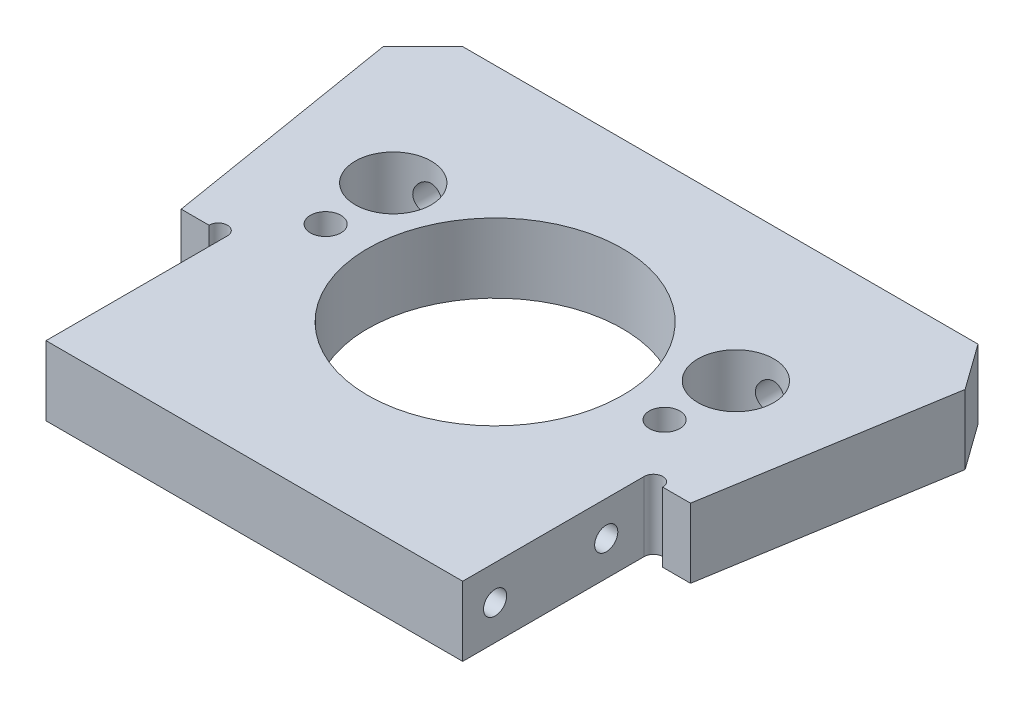
from build123d import *
from OCP.BRepFilletAPI import BRepFilletAPI_MakeChamfer

# Parameters (mm, degrees)
BOSS_EXTRUDE1_DEPTH            = 7.5
CUT_EXTRUDE1_REACH             = 58.013
SKETCH2_R                      = 1
CUT_EXTRUDE1_DIRECTION_2_DEPTH = 57.013391256
CHAMFER1_SIZE                  = 5
CHAMFER1_SIZE2                 = 4.351474633
CUT_EXTRUDE2_REACH             = 57.607
SKETCH3_R                      = 13.75
SKETCH11_W                     = 45
SKETCH11_H                     = 7.5
BOSS_EXTRUDE2_DEPTH            = 5
M4_TAPPED_HOLE1_D              = 3.3
CUT_EXTRUDE3_REACH             = 57.607
SKETCH6_R                      = 4.1
M4_TAPPED_HOLE2_REACH          = 61.725
M4_TAPPED_HOLE2_BORE_R         = 1.65
M3_TAPPED_HOLE1_AT_2_COUNT     = 2
M3_TAPPED_HOLE1_AT_2_PITCH     = 12


with BuildPart() as part:
    # Sketch1 → Boss-Extrude1 (new body)
    with BuildSketch(Plane(origin=(0, 0, 0), x_dir=(1, 0, 0), z_dir=(0, 1, 0))):
        Polygon((-22.5, 0), (22.5, 0), (22.5, 14.6), (27.5, 14.6), (32.5, 45), (-32.5, 45), (-27.5, 14.6), (-22.5, 14.6), align=None)
    extrude(amount=BOSS_EXTRUDE1_DEPTH)

    # Sketch2 → Cut-Extrude1 (cut, up to next)
    with BuildSketch(Plane(origin=(0, 7.5, 0), x_dir=(1, 0, 0), z_dir=(0, 1, 0)), mode=Mode.PRIVATE) as cut_extrude1_sk1:
        with Locations((-23.5, 14.6)):
            Circle(SKETCH2_R)
    cut_extrude1_tool1 = extrude(cut_extrude1_sk1.sketch, amount=-CUT_EXTRUDE1_REACH, mode=Mode.PRIVATE) & part.part
    # Sketch2 → Cut-Extrude1 (cut, up to next)
    with BuildSketch(Plane(origin=(0, 7.5, 0), x_dir=(1, 0, 0), z_dir=(0, 1, 0)), mode=Mode.PRIVATE) as cut_extrude1_sk2:
        with Locations((23.5, 14.6)):
            Circle(SKETCH2_R)
    cut_extrude1_tool2 = extrude(cut_extrude1_sk2.sketch, amount=-CUT_EXTRUDE1_REACH, mode=Mode.PRIVATE) & part.part
    add(cut_extrude1_tool1.solids().sort_by_distance((-23.5, 7.5, -14.6))[0], mode=Mode.SUBTRACT)
    add(cut_extrude1_tool2.solids().sort_by_distance((23.5, 7.5, -14.6))[0], mode=Mode.SUBTRACT)

    # Sketch2 → Cut-Extrude1 direction 2 (cut)
    with BuildSketch(Plane(origin=(0, 7.5, 0), x_dir=(1, 0, 0), z_dir=(0, 1, 0))):
        with Locations((-23.5, 14.6)):
            Circle(SKETCH2_R)
        with Locations((23.5, 14.6)):
            Circle(SKETCH2_R)
    extrude(amount=CUT_EXTRUDE1_DIRECTION_2_DEPTH, mode=Mode.SUBTRACT)

    # Chamfer1: one chamfer whose edges measure the first distance from different faces: ONE call of the kernel's chamfer builder (chamfer() names one face for all edges)
    chamfer1_edges_1 = [part.edges().sort_by_distance(p)[0] for p in [
        (-32.5, 3.75, -45),
    ]]
    chamfer1_side_1 = [part.faces().sort_by_distance(p)[0] for p in [
        (0, 3.75, -45),
    ]]
    chamfer1_edges_2 = [part.edges().sort_by_distance(p)[0] for p in [
        (32.5, 3.75, -45),
    ]]
    chamfer1_side_2 = [part.faces().sort_by_distance(p)[0] for p in [
        (30, 3.75, -29.8),
    ]]
    chamfer1 = BRepFilletAPI_MakeChamfer(part.part.solid().wrapped)
    for e in chamfer1_edges_1:
        chamfer1.Add(CHAMFER1_SIZE, CHAMFER1_SIZE2, e.wrapped, chamfer1_side_1[0].wrapped)  # the first distance lies on this face
    for e in chamfer1_edges_2:
        chamfer1.Add(CHAMFER1_SIZE, CHAMFER1_SIZE2, e.wrapped, chamfer1_side_2[0].wrapped)  # the first distance lies on this face
    add(Compound.cast(chamfer1.Shape()), mode=Mode.REPLACE)

    # Sketch3 → Cut-Extrude2 (cut, up to next)
    with BuildSketch(Plane(origin=(0, 7.5, 0), x_dir=(1, 0, 0), z_dir=(0, 1, 0)), mode=Mode.PRIVATE) as cut_extrude2_sk1:
        with Locations(Location((0, 21, 0), (0, 0, 270))):
            Circle(SKETCH3_R)
    cut_extrude2_tool1 = extrude(cut_extrude2_sk1.sketch, amount=-CUT_EXTRUDE2_REACH, mode=Mode.PRIVATE) & part.part
    add(cut_extrude2_tool1.solids().sort_by_distance((0, 7.5, -21))[0], mode=Mode.SUBTRACT)

    # Sketch11 → Boss-Extrude2 (add)
    with BuildSketch(Plane.XY):
        with Locations((0, 3.75)):
            Rectangle(SKETCH11_W, SKETCH11_H)
    extrude(amount=BOSS_EXTRUDE2_DEPTH)

    # M4 Tapped Hole1 (through all)
    with Locations(Plane(origin=(0, 0, 0), x_dir=(-1, 0, 0), z_dir=(0, -1, 0))):
        with Locations((-18.3, 21), (18.3, 21)):
            Hole(M4_TAPPED_HOLE1_D / 2)

    # Sketch6 → Cut-Extrude3 (cut, up to next)
    with BuildSketch(Plane.XZ, mode=Mode.PRIVATE) as cut_extrude3_sk1:
        with Locations(Location((18.5, -28.5, 0), (0, 0, 270))):
            Circle(SKETCH6_R)
    cut_extrude3_tool1 = extrude(cut_extrude3_sk1.sketch, amount=-CUT_EXTRUDE3_REACH, mode=Mode.PRIVATE) & part.part
    # Sketch6 → Cut-Extrude3 (cut, up to next)
    with BuildSketch(Plane.XZ, mode=Mode.PRIVATE) as cut_extrude3_sk2:
        with Locations(Location((-18.5, -28.5, 0), (0, 0, 270))):
            Circle(SKETCH6_R)
    cut_extrude3_tool2 = extrude(cut_extrude3_sk2.sketch, amount=-CUT_EXTRUDE3_REACH, mode=Mode.PRIVATE) & part.part
    add(cut_extrude3_tool1.solids().sort_by_distance((18.5, 0, -28.5))[0], mode=Mode.SUBTRACT)
    add(cut_extrude3_tool2.solids().sort_by_distance((-18.5, 0, -28.5))[0], mode=Mode.SUBTRACT)

    # M4 Tapped Hole2 bore → M4 Tapped Hole2 (cut, up to next)
    with BuildSketch(Plane(origin=(0, 0, -45), x_dir=(-1, 0, 0), z_dir=(0, 0, -1)), mode=Mode.PRIVATE) as m4_tapped_hole2_sk1:
        with Locations((-18.5, 3.75)):
            Circle(M4_TAPPED_HOLE2_BORE_R)
    m4_tapped_hole2_tool1 = extrude(m4_tapped_hole2_sk1.sketch, amount=-M4_TAPPED_HOLE2_REACH, mode=Mode.PRIVATE) & part.part
    # M4 Tapped Hole2 bore → M4 Tapped Hole2 (cut, up to next)
    with BuildSketch(Plane(origin=(0, 0, -45), x_dir=(-1, 0, 0), z_dir=(0, 0, -1)), mode=Mode.PRIVATE) as m4_tapped_hole2_sk2:
        with Locations((18.5, 3.75)):
            Circle(M4_TAPPED_HOLE2_BORE_R)
    m4_tapped_hole2_tool2 = extrude(m4_tapped_hole2_sk2.sketch, amount=-M4_TAPPED_HOLE2_REACH, mode=Mode.PRIVATE) & part.part
    add(m4_tapped_hole2_tool1.solids().sort_by_distance((18.5, 3.75, -45))[0], mode=Mode.SUBTRACT)
    add(m4_tapped_hole2_tool2.solids().sort_by_distance((-18.5, 3.75, -45))[0], mode=Mode.SUBTRACT)

    # Sketch10 → M3 Tapped Hole1 (revolve, cut)
    with BuildSketch(Plane(origin=(22.5, 3.75, -10.5), x_dir=(0, 0, -1), z_dir=(0, 1, 0))):
        Polygon((0, 0), (0, 10.751075774), (1.25, 10), (1.25, 0), align=None)
    m3_tapped_hole1 = revolve(axis=Axis((28.85, 3.75, -10.5), (-1, 0, 0)), mode=Mode.SUBTRACT)

    # M3 Tapped Hole1 at 2: M3 Tapped Hole1 ×2
    with Locations(*[(0, 0, i * M3_TAPPED_HOLE1_AT_2_PITCH) for i in range(1, M3_TAPPED_HOLE1_AT_2_COUNT)]):
        add(m3_tapped_hole1, mode=Mode.SUBTRACT)

    # Mirror1: M3 Tapped Hole1 across plane
    add(m3_tapped_hole1.mirror(Plane(origin=(0, 0, 0), x_dir=(0, 0, 1), z_dir=(1, 0, 0))), mode=Mode.SUBTRACT)

    # Mirror1 copy 1 sketch → Mirror1 copy 1 (revolve, cut)
    with BuildSketch(Plane(origin=(-22.5, 3.75, 1.5), x_dir=(0, 0, -1), z_dir=(0, 1, 0))):
        Polygon((0, 0), (0, -10.751075774), (1.25, -10), (1.25, 0), align=None)
    revolve(axis=Axis((-28.85, 3.75, 1.5), (-1, 0, 0)), mode=Mode.SUBTRACT)


solid = part.part
